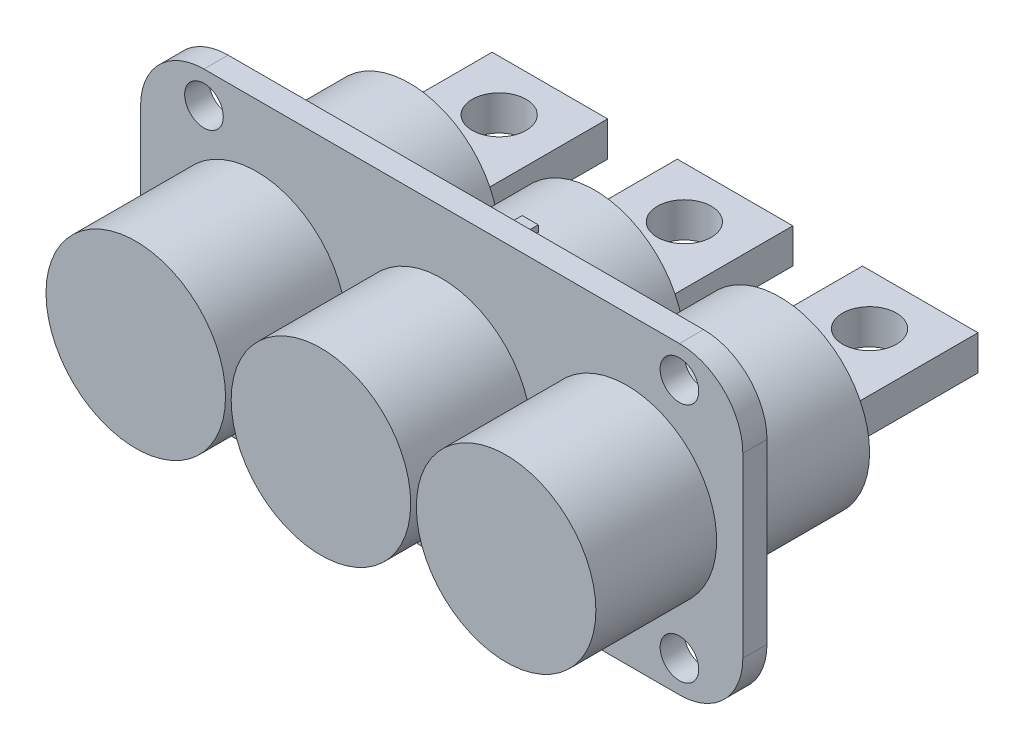
from build123d import *

# Parameters (mm, degrees)
SKETCH1_R                = 14.1605
BOSS_EXTRUDE1_DEPTH      = 43.18
SKETCH3_W                = 18.2245
SKETCH3_H                = 22.1488
SKETCH3_R                = 4.2545
BOSS_EXTRUDE2_DEPTH      = 2.74955
BOSS_EXTRUDE2_DEPTH_BACK = 2.74955
LPATTERN1_COUNT          = 2
LPATTERN1_PITCH          = 29.21
LPATTERN1_2_COUNT        = 2
LPATTERN1_2_PITCH        = 29.21
BOSS_EXTRUDE3_START      = 20.32
SKETCH4_R                = 3.048
BOSS_EXTRUDE3_DEPTH      = 3.81
BOSS_EXTRUDE4_START      = -30.48
BOSS_EXTRUDE4_DEPTH      = 2.54


with BuildPart() as part:
    # Sketch1 → Boss-Extrude1 (new body)
    with BuildSketch(Plane.XY):
        Circle(SKETCH1_R)
    extrude(amount=BOSS_EXTRUDE1_DEPTH)

    # Sketch3 → Boss-Extrude2 (add, two sides)
    with BuildSketch(Plane(origin=(0, 0, 0), x_dir=(1, 0, 0), z_dir=(0, 1, 0))) as boss_extrude2_sk:
        with Locations((0, 11.0744)):
            Rectangle(SKETCH3_W, SKETCH3_H)
        with Locations((0, 14.1478)):
            Circle(SKETCH3_R, mode=Mode.SUBTRACT)
    extrude(amount=BOSS_EXTRUDE2_DEPTH)
    extrude(boss_extrude2_sk.sketch, amount=-BOSS_EXTRUDE2_DEPTH_BACK)


with BuildPart() as lpattern1_1:
    # LPattern1: pattern copy
    add(part.part.moved(Location(Vector(1, 0, 0) * (1 * LPATTERN1_PITCH))))


with BuildPart() as lpattern1_2_1:
    # LPattern1 2: pattern copy
    add(part.part.moved(Location(Vector(-1, 0, 0) * (1 * LPATTERN1_2_PITCH))))


with BuildPart() as lpattern1_2_2:
    # LPattern1 2: pattern copy
    add(lpattern1_1.part.moved(Location(Vector(-1, 0, 0) * (1 * LPATTERN1_2_PITCH))))


with BuildPart() as part_1:
    add(part.part)

    add(lpattern1_1.part)  # Boss-Extrude3 merges LPattern1_1

    add(lpattern1_2_1.part)  # Boss-Extrude3 merges LPattern1 2_1

    add(lpattern1_2_2.part)  # Boss-Extrude3 merges LPattern1 2_2
    # Sketch4 → Boss-Extrude3 (add)
    with BuildSketch(Plane.XY.offset(BOSS_EXTRUDE3_START)):
        with BuildLine():
            Line((-37.5, 24), (37.5, 24))
            ThreePointArc((37.5, 24), (44.571067812, 21.071067812), (47.5, 14))
            Line((47.5, 14), (47.5, -14))
            ThreePointArc((47.5, -14), (44.571067812, -21.071067812), (37.5, -24))
            Line((37.5, -24), (-37.5, -24))
            ThreePointArc((-37.5, -24), (-44.571067812, -21.071067812), (-47.5, -14))
            Line((-47.5, -14), (-47.5, 14))
            ThreePointArc((-47.5, 14), (-44.571067812, 21.071067812), (-37.5, 24))
        make_face()
        with Locations((-37.5, 19)):
            Circle(SKETCH4_R, mode=Mode.SUBTRACT)
        with Locations((37.5, 19)):
            Circle(SKETCH4_R, mode=Mode.SUBTRACT)
        with Locations((37.5, -19)):
            Circle(SKETCH4_R, mode=Mode.SUBTRACT)
        with Locations((-37.5, -19)):
            Circle(SKETCH4_R, mode=Mode.SUBTRACT)
    extrude(amount=BOSS_EXTRUDE3_DEPTH)

    # Sketch6 → Boss-Extrude4 (add)
    with BuildSketch(Plane.XY.offset(43.18).offset(BOSS_EXTRUDE4_START)):
        with BuildLine():
            Line((-1.27, 14.103434342), (-1.27, 15.119434342))
            Line((-1.27, 15.119434342), (1.27, 15.119434342))
            Line((1.27, 15.119434342), (1.27, 14.103434342))
            ThreePointArc((1.27, 14.103434342), (0, 14.1605), (-1.27, 14.103434342))
        make_face()
    extrude(amount=-BOSS_EXTRUDE4_DEPTH)


solid = part_1.part
